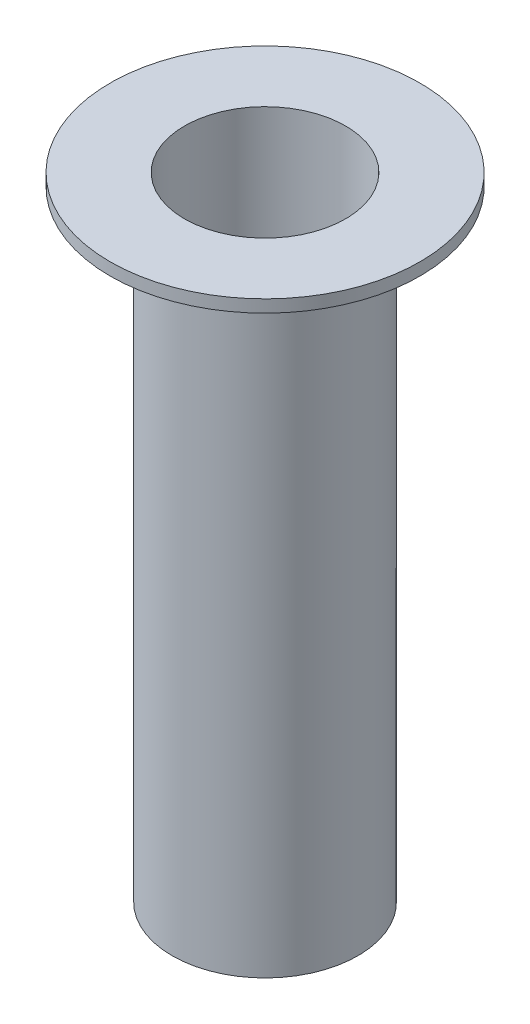
from build123d import *

# Parameters (mm, degrees)
SKETCH1_R           = 6
SKETCH1_R_2         = 5.2
BOSS_EXTRUDE1_DEPTH = 20
SKETCH4_R           = 10
SKETCH4_R_2         = 5.2
BOSS_EXTRUDE3_DEPTH = 0.8


with BuildPart() as part:
    # Sketch1 → Boss-Extrude1 (new body, symmetric)
    with BuildSketch(Plane(origin=(0, 0, 0), x_dir=(1, 0, 0), z_dir=(0, 1, 0))):
        Circle(SKETCH1_R)
        Circle(SKETCH1_R_2, mode=Mode.SUBTRACT)
    extrude(amount=BOSS_EXTRUDE1_DEPTH, both=True)

    # Sketch4 → Boss-Extrude3 (add)
    with BuildSketch(Plane(origin=(0, 20, 0), x_dir=(1, 0, 0), z_dir=(0, 1, 0))):
        Circle(SKETCH4_R)
        Circle(SKETCH4_R_2, mode=Mode.SUBTRACT)
    extrude(amount=BOSS_EXTRUDE3_DEPTH)


solid = part.part
